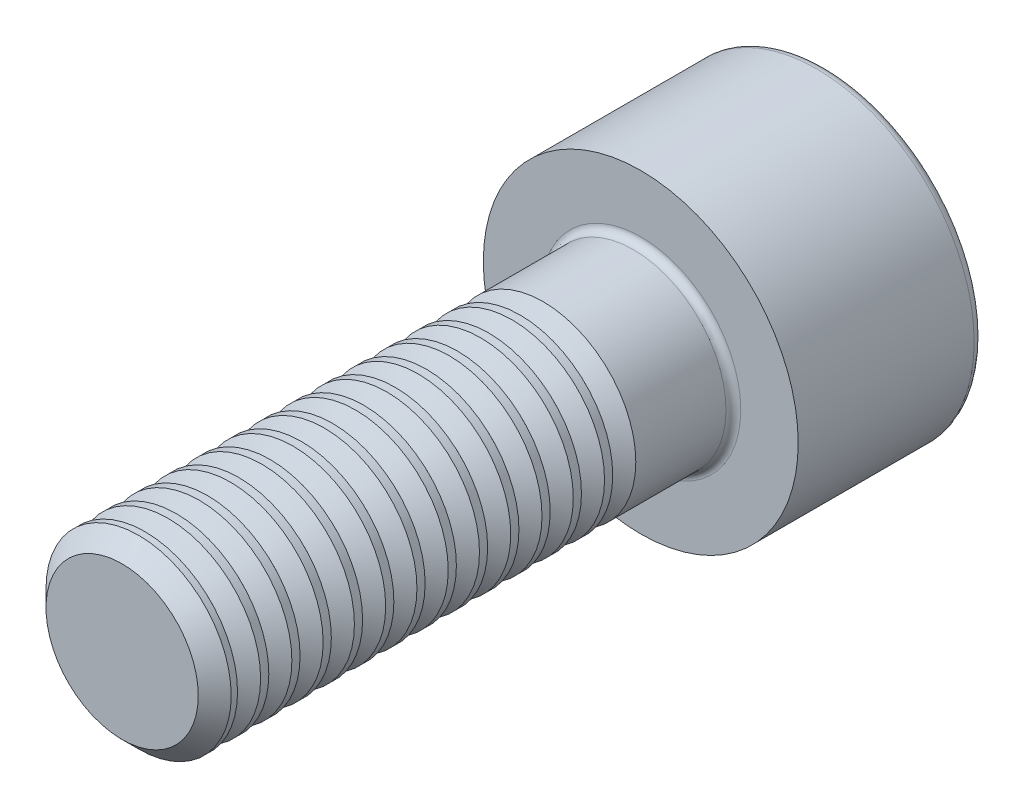
from build123d import *

# Parameters (mm, degrees)
SCHIZZO1_R                   = 4.25
ESTRUSIONE_ESTRUSIONE1_DEPTH = 5
SCHIZZO2_R                   = 2.5
ESTRUSIONE_ESTRUSIONE2_DEPTH = 14
TAGLIO_ESTRUSIONE1_DEPTH     = 2.5
RACCORDO1_R                  = 0.25
RACCORDO2_R                  = 0.2
SMUSSO1_SIZE                 = 0.445
RIPETIZIONE_A_L1_COUNT       = 13
RIPETIZIONE_A_L1_PITCH       = 0.844


with BuildPart() as part:
    # Schizzo1 → Estrusione-Estrusione1 (new body)
    with BuildSketch(Plane.XY):
        Circle(SCHIZZO1_R)
    extrude(amount=ESTRUSIONE_ESTRUSIONE1_DEPTH)

    # Schizzo2 → Estrusione-Estrusione2 (add)
    with BuildSketch(Plane.XY.offset(5)):
        Circle(SCHIZZO2_R)
    extrude(amount=ESTRUSIONE_ESTRUSIONE2_DEPTH)

    # Schizzo3 → Taglio-Estrusione1 (cut)
    with BuildSketch(Plane(origin=(0, 0, 0), x_dir=(-1, 0, 0), z_dir=(0, 0, -1))):
        Polygon((0, 2.358), (-2.042087902, 1.179), (-2.042087902, -1.179), (0, -2.358), (2.042087902, -1.179), (2.042087902, 1.179), align=None)
    extrude(amount=-TAGLIO_ESTRUSIONE1_DEPTH, mode=Mode.SUBTRACT)

    # Raccordo1
    raccordo1_edges = [part.edges().sort_by_distance(p)[0] for p in [
        (-4.25, 0, 0),
    ]]
    fillet(raccordo1_edges, radius=RACCORDO1_R)

    # Raccordo2
    raccordo2_edges = [part.edges().sort_by_distance(p)[0] for p in [
        (-2.5, 0, 5),
    ]]
    fillet(raccordo2_edges, radius=RACCORDO2_R)

    # Smusso1
    smusso1_edges = [part.edges().sort_by_distance(p)[0] for p in [
        (-2.5, 0, 19),
    ]]
    chamfer(smusso1_edges, length=SMUSSO1_SIZE)

    # Schizzo4 → Taglia-Rivoluzione1 (revolve, cut)
    with BuildSketch(Plane(origin=(0, 0, 0), x_dir=(0, 0, -1), z_dir=(1, 0, 0))):
        Polygon((-7.945118296, -2.055), (-8.25671065, -2.5), (-8.25671065, -3.125), (-7.633525941, -3.125), (-7.633525941, -2.5), align=None)
    taglia_rivoluzione1 = revolve(axis=Axis((0, 0, 0), (0, 0, 1)), mode=Mode.SUBTRACT)

    # Ripetizione a L1: Taglia-Rivoluzione1 ×13
    with Locations(*[(0, 0, i * RIPETIZIONE_A_L1_PITCH) for i in range(1, RIPETIZIONE_A_L1_COUNT)]):
        add(taglia_rivoluzione1, mode=Mode.SUBTRACT)

    # Schizzo5 → Taglia-Rivoluzione2 (revolve, cut)
    with BuildSketch(Plane(origin=(0, 0, 0), x_dir=(0, 0, -1), z_dir=(1, 0, 0))):
        Polygon((0, -2.042), (-2.5, -2.042), (-3.67894925, 0), (0, 0), align=None)
    revolve(axis=Axis((0, 0, 3.67894925), (0, 0, -1)), mode=Mode.SUBTRACT)


solid = part.part
